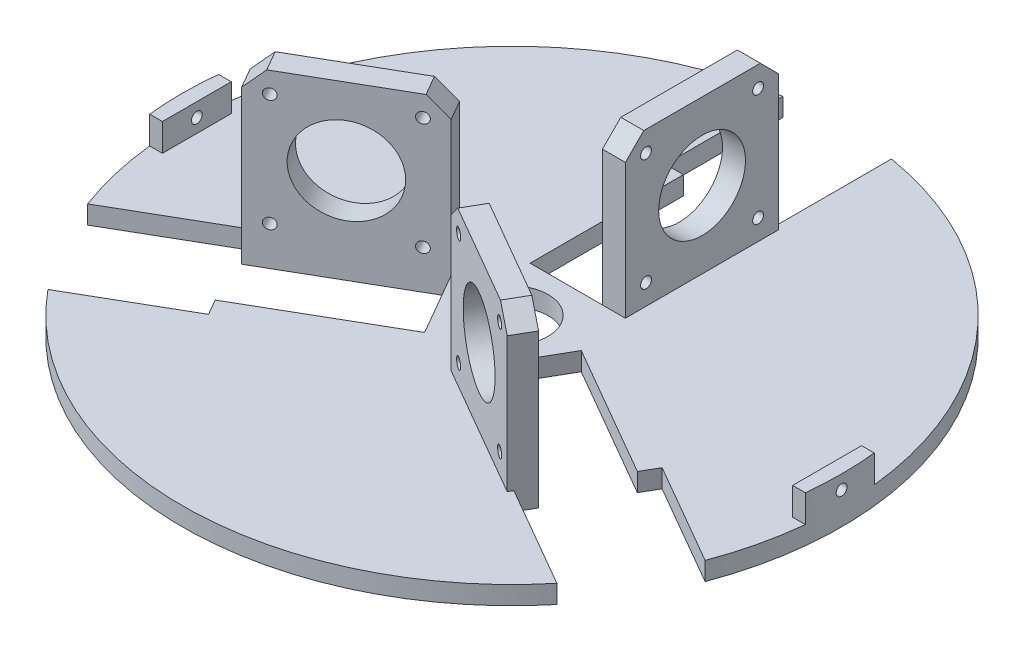
from build123d import *

# Parameters (mm, degrees)
SKETCH1_R           = 10
BASE_DEPTH          = 5.08
SKETCH2_R           = 12
SKETCH2_R_2         = 1.5
MOTOREXTRUDE_DEPTH  = 6.35
CIRPATTERN3_COUNT   = 3
CIRPATTERN3_ANGLE   = 240
BOSS_EXTRUDE1_DEPTH = 12.7
SKETCH3_R           = 1.5
CUT_EXTRUDE1_DEPTH  = 5.018


with BuildPart() as part:
    # Sketch1 → Base (new body)
    with BuildSketch(Plane(origin=(0, 0, 0), x_dir=(1, 0, 0), z_dir=(0, 1, 0))):
        with BuildLine():
            Line((-10, 15), (-10, 57.3926))
            Line((-10, 57.3926), (-15, 57.3926))
            Line((-15, 57.3926), (-15, 89.897161246))
            ThreePointArc((-15, 89.897161246), (-78.929555301, 45.57), (-85.353225367, -31.958199566))
            Line((-85.353225367, -31.958199566), (-57.203449589, -15.705918943))
            Line((-57.203449589, -15.705918943), (-54.703449589, -20.036045962))
            Line((-54.703449589, -20.036045962), (-17.990381057, 1.160254038))
            Line((-17.990381057, 1.160254038), (-7.990381057, -16.160254038))
            Line((-7.990381057, -16.160254038), (-44.703449589, -37.356554038))
            Line((-44.703449589, -37.356554038), (-42.203449589, -41.686681057))
            Line((-42.203449589, -41.686681057), (-70.353225367, -57.93896168))
            ThreePointArc((-70.353225367, -57.93896168), (0, -91.14), (70.353225367, -57.93896168))
            Line((70.353225367, -57.93896168), (42.203449589, -41.686681057))
            Line((42.203449589, -41.686681057), (44.703449589, -37.356554038))
            Line((44.703449589, -37.356554038), (7.990381057, -16.160254038))
            Line((7.990381057, -16.160254038), (17.990381057, 1.160254038))
            Line((17.990381057, 1.160254038), (54.703449589, -20.036045962))
            Line((54.703449589, -20.036045962), (57.203449589, -15.705918943))
            Line((57.203449589, -15.705918943), (85.353225367, -31.958199566))
            ThreePointArc((85.353225367, -31.958199566), (78.929555301, 45.57), (15, 89.897161246))
            Line((15, 89.897161246), (15, 57.3926))
            Line((15, 57.3926), (10, 57.3926))
            Line((10, 57.3926), (10, 15))
            Line((10, 15), (-10, 15))
        make_face()
        Circle(SKETCH1_R, mode=Mode.SUBTRACT)
    extrude(amount=BASE_DEPTH)

    # Sketch2 → MotorExtrude (add)
    with BuildSketch(Plane(origin=(-5, 0, 8.660254038), x_dir=(-0.866025404, 0, -0.5), z_dir=(0.5, 0, -0.866025404))):
        Polygon((-15, 5.08), (-57.3926, 5.08), (-57.3926, 42.39), (-52.3126, 47.47), (-20.08, 47.47), (-15, 42.39), align=None)
        with Locations((-36.1963, 26.275)):
            Circle(SKETCH2_R, mode=Mode.SUBTRACT)
        with Locations((-20.701824858, 41.768524843)):
            Circle(SKETCH2_R_2, mode=Mode.SUBTRACT)
        with Locations((-20.702775157, 10.780524858)):
            Circle(SKETCH2_R_2, mode=Mode.SUBTRACT)
        with Locations((-51.690775142, 10.781475157)):
            Circle(SKETCH2_R_2, mode=Mode.SUBTRACT)
        with Locations((-51.689824843, 41.769475142)):
            Circle(SKETCH2_R_2, mode=Mode.SUBTRACT)
    motorextrude = extrude(amount=-MOTOREXTRUDE_DEPTH)

    # CirPattern3: MotorExtrude ×3 about axis
    cirpattern3_axis = Axis((0, 0, 0), (0, 1, 0))
    for i in range(1, CIRPATTERN3_COUNT):
        add(motorextrude.rotate(cirpattern3_axis, i * CIRPATTERN3_ANGLE / (CIRPATTERN3_COUNT - 1)))

    # Sketch1_7 → Boss-Extrude1 (add)
    with BuildSketch(Plane(origin=(0, 0, 0), x_dir=(1, 0, 0), z_dir=(0, 1, 0))):
        with BuildLine():
            Line((-87.122, 9.525), (-90.640906742, 9.525))
            ThreePointArc((-90.640906742, 9.525), (-91.14, 0), (-90.640906742, -9.525))
            Line((-90.640906742, -9.525), (-87.122, -9.525))
            Line((-87.122, -9.525), (-87.122, 9.525))
        make_face()
        with BuildLine():
            Line((87.122, 9.525), (87.122, -9.525))
            Line((87.122, -9.525), (90.640906742, -9.525))
            ThreePointArc((90.640906742, -9.525), (91.14, 0), (90.640906742, 9.525))
            Line((90.640906742, 9.525), (87.122, 9.525))
        make_face()
    extrude(amount=BOSS_EXTRUDE1_DEPTH)

    # Sketch3 → Cut-Extrude1 (cut, through all)
    with BuildSketch(Plane.ZY.offset(-87.122)):
        with Locations((0, 8.89)):
            Circle(SKETCH3_R)
    cut_extrude1 = extrude(amount=-CUT_EXTRUDE1_DEPTH, mode=Mode.SUBTRACT)

    # Mirror1: Cut-Extrude1 across plane
    add(cut_extrude1.mirror(Plane(origin=(0, 0, 0), x_dir=(0, 0, 1), z_dir=(1, 0, 0))), mode=Mode.SUBTRACT)


solid = part.part
